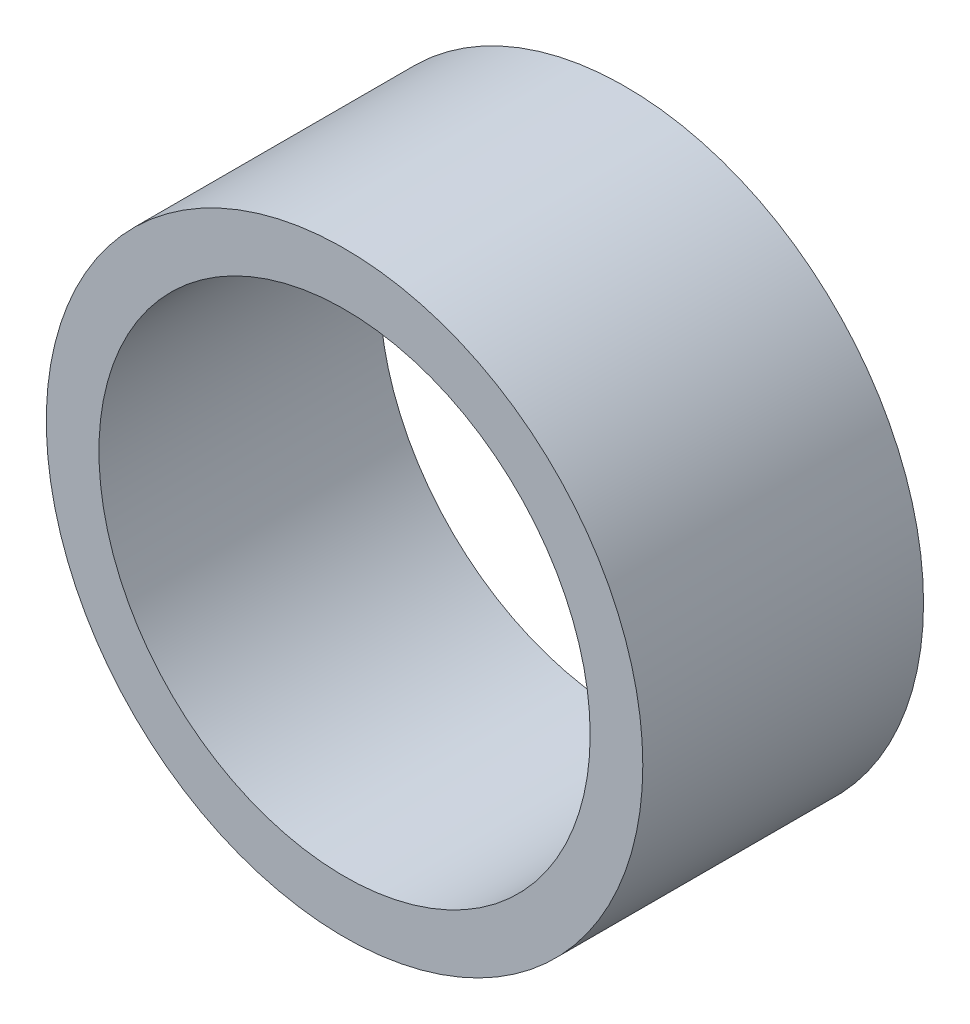
from build123d import *

# Parameters (mm, degrees)
SKETCH_2_R      = 8.5
SKETCH_2_R_2    = 7
EXTRUDE_2_DEPTH = 8


with BuildPart() as part:
    # Эскиз2 → Бобышка-Вытянуть2 (new body)
    with BuildSketch(Plane.XY):
        Circle(SKETCH_2_R)
        Circle(SKETCH_2_R_2, mode=Mode.SUBTRACT)
    extrude(amount=EXTRUDE_2_DEPTH)


solid = part.part
